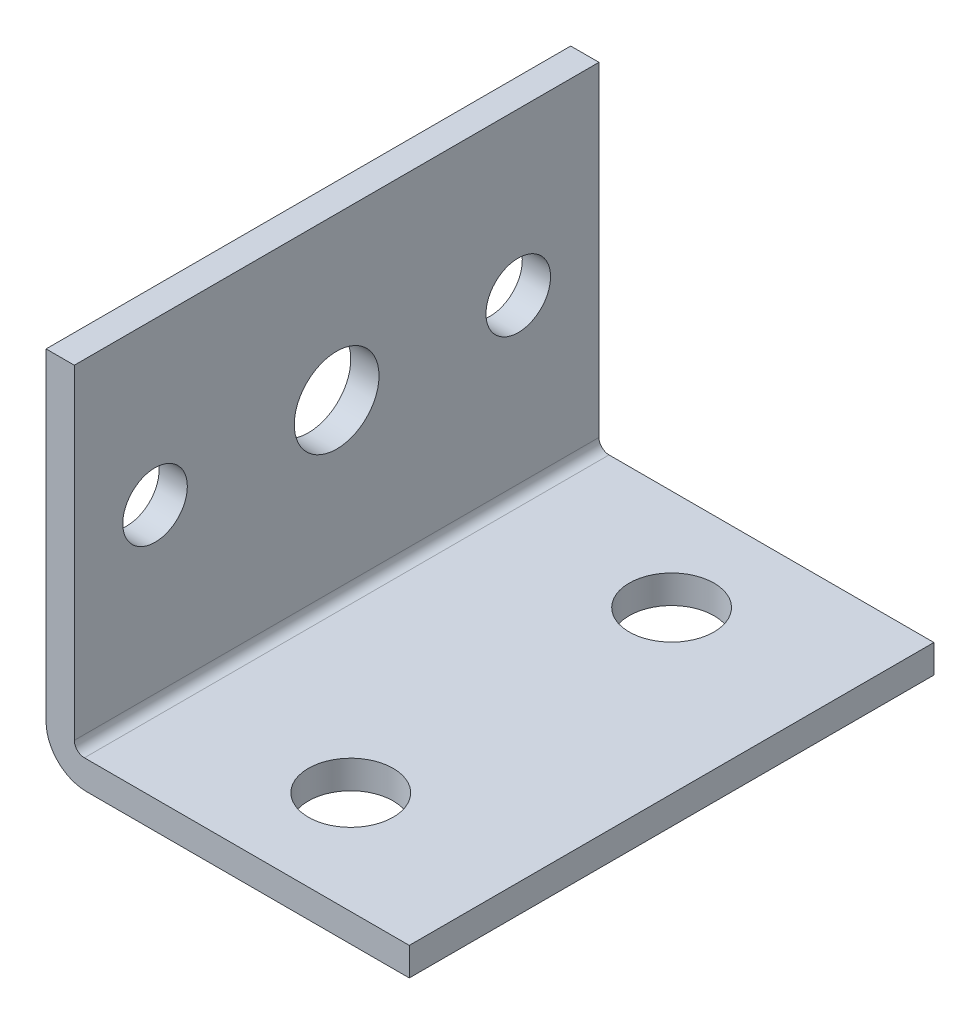
from build123d import *

# Parameters (mm, degrees)
BOSS_EXTRUDE1_DEPTH = 66.04
FILLET1_R           = 1.27
FILLET3_R           = 5.08
SKETCH2_R           = 5.334
SKETCH2_R_2         = 4.064
CUT_EXTRUDE1_DEPTH  = 66.04
SKETCH3_R           = 5.334
CUT_EXTRUDE2_DEPTH  = 66.04


with BuildPart() as part:
    # Sketch1 → Boss-Extrude1 (new body)
    with BuildSketch(Plane.XY):
        Polygon((-20.634190635, 26.453063941), (-20.634190635, -19.266936059), (25.085809365, -19.266936059), (25.085809365, -15.710936059), (-17.078190635, -15.710936059), (-17.078190635, 26.453063941), align=None)
    extrude(amount=-BOSS_EXTRUDE1_DEPTH)

    # Fillet1
    fillet1_edges = [part.edges().sort_by_distance(p)[0] for p in [
        (-17.078190635, -15.710936059, -33.02),
    ]]
    fillet(fillet1_edges, radius=FILLET1_R)

    # Fillet3
    fillet3_edges = [part.edges().sort_by_distance(p)[0] for p in [
        (-20.634190635, -19.266936059, -33.02),
    ]]
    fillet(fillet3_edges, radius=FILLET3_R)

    # Sketch2 → Cut-Extrude1 (cut)
    with BuildSketch(Plane.ZY.offset(20.634190635)):
        with Locations((-33.02, 6.133063941)):
            Circle(SKETCH2_R)
        with Locations((-55.88, 6.133063941)):
            Circle(SKETCH2_R_2)
        with Locations((-10.16, 6.133063941)):
            Circle(SKETCH2_R_2)
    extrude(amount=-CUT_EXTRUDE1_DEPTH, mode=Mode.SUBTRACT)

    # Sketch3 → Cut-Extrude2 (cut)
    with BuildSketch(Plane(origin=(0, -19.266936059, 0), x_dir=(-1, 0, 0), z_dir=(0, -1, 0))):
        with Locations((-4.765809365, 12.954)):
            Circle(SKETCH3_R)
        with Locations((-4.765809365, 53.34)):
            Circle(SKETCH3_R)
    extrude(amount=-CUT_EXTRUDE2_DEPTH, mode=Mode.SUBTRACT)


solid = part.part
